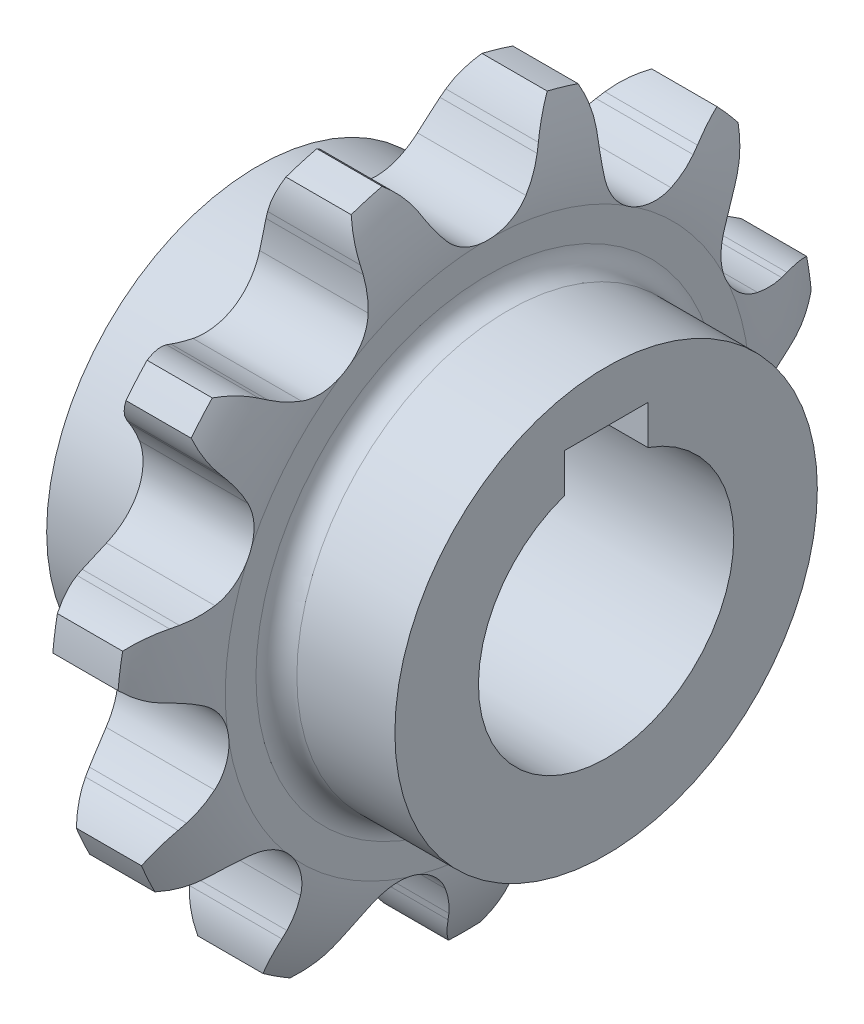
from build123d import *

# Parameters (mm, degrees)
EXTRUDECUTONE_DEPTH     = 17.480659201
PATTERNONE_COUNT        = 11
CUT_EXTRUDEB_DEPTH      = 108.253634747
CUT_EXTRUDEB_DEPTH_BACK = 108.253634747
SKETCHKEY_W             = 18
SKETCHKEY_H             = 19.400000095
CUT_EXTRUDE_3_REACH     = 113.445
SKETCH_3_R              = 27.5
SKETCH_4_R              = 45.5
EXTRUDE_1_DEPTH         = 20.02
EXTRUDE_START           = 20.02
SKETCH_5_R              = 45.5
EXTRUDE_2_DEPTH         = 20.02


with BuildPart() as part:
    # Sketch1 → Revolve 2 (revolve)
    with BuildSketch(Plane.XY):
        with BuildLine():
            Line((-17.480659201, 0), (-17.480659201, 45.5))
            Line((-17.480659201, 45.5), (-16.380427361, 45.5))
            ThreePointArc((-16.380427361, 45.5), (-13.26850178, 46.78900178), (-11.9795, 49.900927361))
            Line((-11.9795, 49.900927361), (-11.9795, 56.502318401))
            ThreePointArc((-11.9795, 56.502318401), (-10.684084049, 66.067410146), (-7.0265, 75))
            Line((-7.0265, 75), (7.0265, 75))
            ThreePointArc((7.0265, 75), (10.684084049, 66.067410146), (11.9795, 56.502318401))
            Line((11.9795, 56.502318401), (11.9795, 49.900927361))
            ThreePointArc((11.9795, 49.900927361), (13.26850178, 46.78900178), (16.380427361, 45.5))
            Line((16.380427361, 45.5), (17.480659201, 45.5))
            Line((17.480659201, 45.5), (17.480659201, 0))
            Line((17.480659201, 0), (-17.480659201, 0))
        make_face()
    revolve(axis=Axis((-4, 0, 0), (1, 0, 0)))

    # Sketch2 → ExtrudeCutOne (cut, symmetric)
    with BuildSketch(Plane(origin=(0, 0, 0), x_dir=(0, 0, -1), z_dir=(1, 0, 0))):
        with BuildLine():
            Line((12.184520951, 65.743142189), (12.938850615, 67.189393505))
            ThreePointArc((12.938850615, 67.189393505), (15.037112508, 70.299837164), (17.777503523, 72.862612968))
            ThreePointArc((17.777503523, 72.862612968), (0, 75), (-17.777503523, 72.862612968))
            ThreePointArc((-17.777503523, 72.862612968), (-15.037112508, 70.299837164), (-12.938850615, 67.189393505))
            Line((-12.938850615, 67.189393505), (-12.184520951, 65.743142189))
            ThreePointArc((-12.184520951, 65.743142189), (-10.513664208, 62.937218082), (-8.537970632, 60.336909016))
            ThreePointArc((-8.537970632, 60.336909016), (0, 56.396743401), (8.537970632, 60.336909016))
            ThreePointArc((8.537970632, 60.336909016), (10.513664208, 62.937218082), (12.184520951, 65.743142189))
        make_face()
    extrudecutone = extrude(amount=EXTRUDECUTONE_DEPTH, both=True, mode=Mode.SUBTRACT)

    # PatternOne: ExtrudeCutOne ×11 about axis
    patternone_axis = Axis((-4, 0, 0), (1, 0, 0))
    for i in range(1, PATTERNONE_COUNT):
        add(extrudecutone.rotate(patternone_axis, i * 360 / PATTERNONE_COUNT), mode=Mode.SUBTRACT)

    # SketchKey → Cut-ExtrudeB (cut, two sides: drawn at the far end of the back side and taken through both)
    with BuildSketch(Plane(origin=(0, 0, 0), x_dir=(0, 0, -1), z_dir=(1, 0, 0)).offset(-CUT_EXTRUDEB_DEPTH_BACK)):
        with Locations((0, 24.700000048)):
            Rectangle(SKETCHKEY_W, SKETCHKEY_H)
    extrude(amount=CUT_EXTRUDEB_DEPTH + CUT_EXTRUDEB_DEPTH_BACK, mode=Mode.SUBTRACT)

    # 草图3 → 切除-拉伸3 (cut, up to next)
    with BuildSketch(Plane(origin=(17.480659201, 0, 0), x_dir=(0, 0, -1), z_dir=(1, 0, 0)), mode=Mode.PRIVATE) as cut_extrude_3_sk1:
        Circle(SKETCH_3_R)
    cut_extrude_3_tool1 = extrude(cut_extrude_3_sk1.sketch, amount=-CUT_EXTRUDE_3_REACH, mode=Mode.PRIVATE) & part.part
    add(cut_extrude_3_tool1.solids().sort_by_distance((17.480659, 0, 0))[0], mode=Mode.SUBTRACT)

    # 草图4 → 凸台-拉伸1 (add)
    with BuildSketch(Plane.ZY.offset(17.480659201)):
        Circle(SKETCH_4_R)
        with BuildLine():
            Line((9, 34.400000095), (9, 25.98557292))
            ThreePointArc((9, 25.98557292), (0, -27.5), (-9, 25.98557292))
            Line((-9, 25.98557292), (-9, 34.400000095))
            Line((-9, 34.400000095), (9, 34.400000095))
        make_face(mode=Mode.SUBTRACT)
    extrude(amount=EXTRUDE_1_DEPTH)

    # 草图5 → 凸台-拉伸2 (add)
    with BuildSketch(Plane(origin=(17.480659201, 0, 0), x_dir=(0, 0, -1), z_dir=(1, 0, 0)).offset(EXTRUDE_START)):
        Circle(SKETCH_5_R)
        with BuildLine():
            Line((9, 25.98557292), (9, 34.400000095))
            Line((9, 34.400000095), (-9, 34.400000095))
            Line((-9, 34.400000095), (-9, 25.98557292))
            ThreePointArc((-9, 25.98557292), (0, -27.5), (9, 25.98557292))
        make_face(mode=Mode.SUBTRACT)
    extrude(amount=-EXTRUDE_2_DEPTH)


solid = part.part
